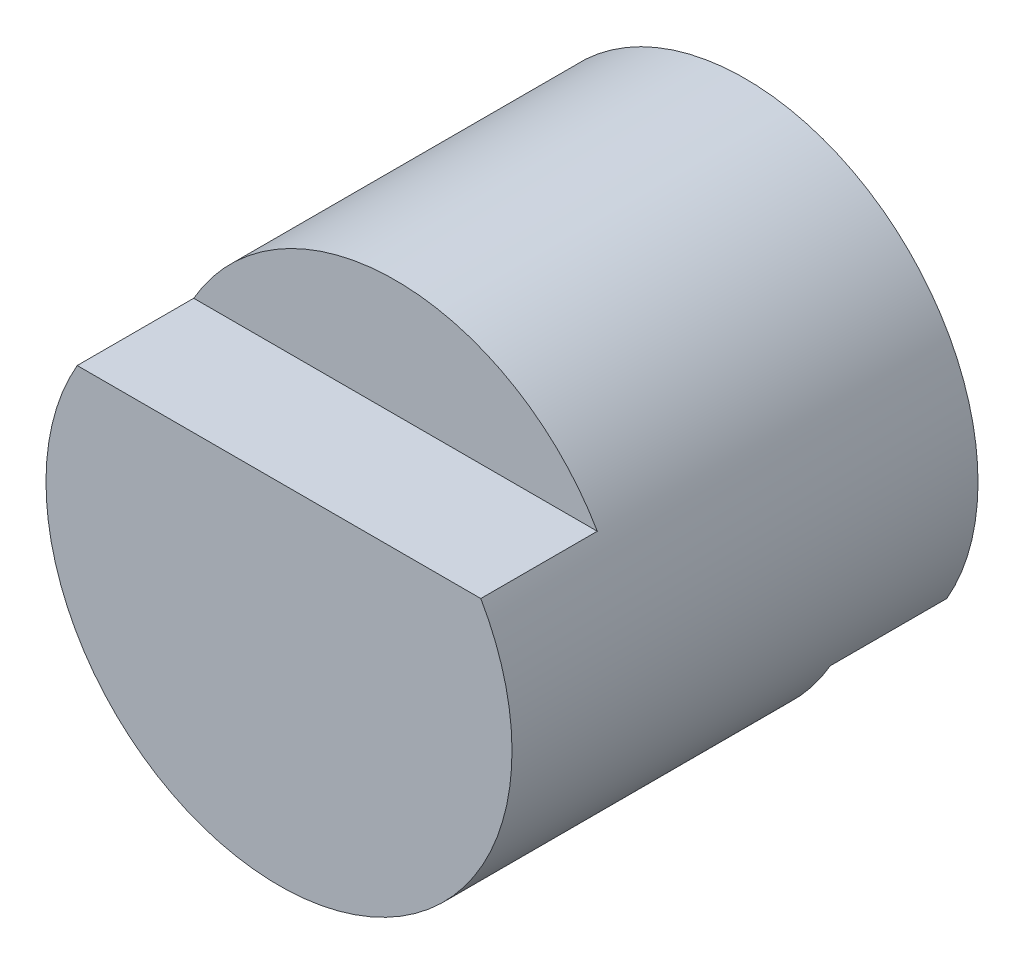
from build123d import *

# Parameters (mm, degrees)
SKETCH1_R           = 2
BOSS_EXTRUDE1_DEPTH = 4
CUT_EXTRUDE2_DEPTH  = 1
CUT_EXTRUDE3_DEPTH  = 1


with BuildPart() as part:
    # Sketch1 → Boss-Extrude1 (new body)
    with BuildSketch(Plane.XY):
        Circle(SKETCH1_R)
    extrude(amount=BOSS_EXTRUDE1_DEPTH)

    # Sketch2 → Cut-Extrude2 (cut)
    with BuildSketch(Plane.XY.offset(4)):
        with BuildLine():
            Line((-1.732050808, 1), (1.732050808, 1))
            ThreePointArc((1.732050808, 1), (0, 2), (-1.732050808, 1))
        make_face()
    extrude(amount=-CUT_EXTRUDE2_DEPTH, mode=Mode.SUBTRACT)

    # Sketch4 → Cut-Extrude3 (cut)
    with BuildSketch(Plane(origin=(0, 0, 0), x_dir=(-1, 0, 0), z_dir=(0, 0, -1))):
        with BuildLine():
            Line((-1.732050808, -1), (1.732050808, -1))
            ThreePointArc((1.732050808, -1), (0, -2), (-1.732050808, -1))
        make_face()
    extrude(amount=-CUT_EXTRUDE3_DEPTH, mode=Mode.SUBTRACT)


solid = part.part
